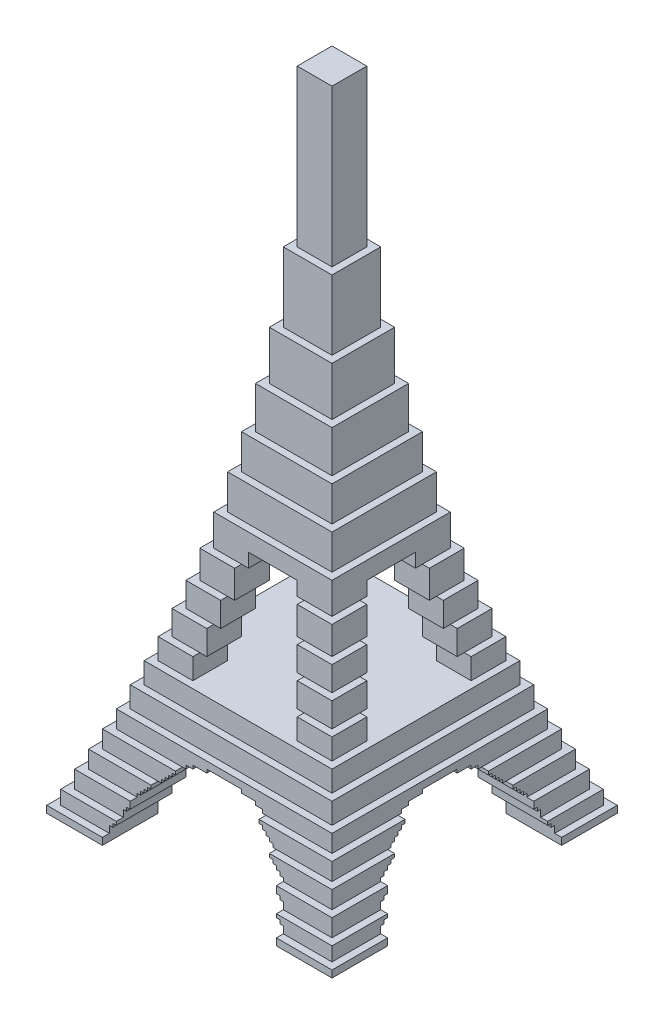
from build123d import *

# Parameters (mm, degrees)
SKIZZE4_W                            = 41
SKIZZE4_H                            = 108
AUFSATZ_LINEAR_AUSTRAGEN2_DEPTH      = 20.5
AUFSATZ_LINEAR_AUSTRAGEN2_DEPTH_BACK = 20.5
SCHNITT_LINEAR_AUSTRAGEN1_DEPTH      = 21.5
SCHNITT_LINEAR_AUSTRAGEN2_DEPTH      = 21.5
SCHNITT_LINEAR_AUSTRAGEN5_DEPTH      = 21.5
SPIEGELN1_COPY_1_DEPTH               = 21.5
SPIEGELN1_COPY_2_DEPTH               = 21.5
SPIEGELN1_COPY_3_DEPTH               = 21.5


with BuildPart() as part:
    # Skizze4 → Aufsatz-Linear austragen2 (new body, two sides)
    with BuildSketch(Plane.XY) as aufsatz_linear_austragen2_sk:
        with Locations((0, 54)):
            Rectangle(SKIZZE4_W, SKIZZE4_H)
    extrude(amount=AUFSATZ_LINEAR_AUSTRAGEN2_DEPTH)
    extrude(aufsatz_linear_austragen2_sk.sketch, amount=-AUFSATZ_LINEAR_AUSTRAGEN2_DEPTH_BACK)

    # Skizze2 → Schnitt-Linear austragen1 (cut, symmetric)
    with BuildSketch(Plane.XY):
        Polygon((-12.5, 0), (-12.5, 2), (-12, 2), (-12, 2.5), (-11.5, 2.5), (-11.5, 4), (-11, 4), (-11, 4.5), (-10.5, 4.5), (-10.5, 6), (-10, 6), (-10, 6.5), (-9.5, 6.5), (-9.5, 7), (-9, 7), (-9, 7.5), (-8.5, 7.5), (-8.5, 8), (-8, 8), (-8, 8.5), (-7.5, 8.5), (-7.5, 9), (-7, 9), (-7, 9.5), (-6.5, 9.5), (-6.5, 10), (-6, 10), (-6, 10.5), (-5.5, 10.5), (-5.5, 11), (-4.5, 11), (-4.5, 11.5), (-2.5, 11.5), (-2.5, 12), (0, 12), (0, 0), align=None)
    schnitt_linear_austragen1 = extrude(amount=SCHNITT_LINEAR_AUSTRAGEN1_DEPTH, both=True, mode=Mode.SUBTRACT)

    # Skizze5 → Schnitt-Linear austragen2 (cut, symmetric)
    with BuildSketch(Plane.XY):
        Polygon((-20.5, 0), (-30.5, 0), (-30.5, 118), (0, 118), (0, 93), (-2.5, 93), (-2.5, 70.5), (-3.5, 70.5), (-3.5, 60.5), (-4.5, 60.5), (-4.5, 53.5), (-5.5, 53.5), (-5.5, 47.5), (-6.5, 47.5), (-6.5, 42.5), (-7.5, 42.5), (-7.5, 37.5), (-8.5, 37.5), (-8.5, 33), (-9.5, 33), (-9.5, 29), (-10.5, 29), (-10.5, 25.5), (-11.5, 25.5), (-11.5, 22), (-12.5, 22), (-12.5, 19), (-13.5, 19), (-13.5, 16), (-14.5, 16), (-14.5, 13), (-15.5, 13), (-15.5, 10.5), (-16.5, 10.5), (-16.5, 8), (-17.5, 8), (-17.5, 5.5), (-18.5, 5.5), (-18.5, 3), (-19.5, 3), (-19.5, 1), (-20.5, 1), align=None)
    schnitt_linear_austragen2 = extrude(amount=SCHNITT_LINEAR_AUSTRAGEN2_DEPTH, both=True, mode=Mode.SUBTRACT)

    # Skizze6 → Schnitt-Linear austragen5 (cut, symmetric)
    with BuildSketch(Plane.XY):
        Polygon((0, 19), (-7.5, 19), (-7.5, 22), (-6.5, 22), (-6.5, 25.5), (-5.5, 25.5), (-5.5, 29), (-4.5, 29), (-4.5, 33), (-3.5, 33), (-3.5, 35), (0, 35), align=None)
    schnitt_linear_austragen5 = extrude(amount=SCHNITT_LINEAR_AUSTRAGEN5_DEPTH, both=True, mode=Mode.SUBTRACT)

    # Spiegeln2: Schnitt-Linear austragen1, Schnitt-Linear austragen2, Schnitt-Linear austragen5 across plane
    add(schnitt_linear_austragen1.mirror(Plane(origin=(0, 0, 0), x_dir=(0, 0, 1), z_dir=(1, 0, 0))), mode=Mode.SUBTRACT)
    add(schnitt_linear_austragen2.mirror(Plane(origin=(0, 0, 0), x_dir=(0, 0, 1), z_dir=(1, 0, 0))), mode=Mode.SUBTRACT)
    add(schnitt_linear_austragen5.mirror(Plane(origin=(0, 0, 0), x_dir=(0, 0, 1), z_dir=(1, 0, 0))), mode=Mode.SUBTRACT)

    # Spiegeln1: Schnitt-Linear austragen5, Schnitt-Linear austragen1, Schnitt-Linear austragen2 across plane
    add(schnitt_linear_austragen5.mirror(Plane(origin=(0, 0, 0), x_dir=(-0.707106781, 0, 0.707106781), z_dir=(0.707106781, 0, 0.707106781))), mode=Mode.SUBTRACT)
    add(schnitt_linear_austragen1.mirror(Plane(origin=(0, 0, 0), x_dir=(-0.707106781, 0, 0.707106781), z_dir=(0.707106781, 0, 0.707106781))), mode=Mode.SUBTRACT)
    add(schnitt_linear_austragen2.mirror(Plane(origin=(0, 0, 0), x_dir=(-0.707106781, 0, 0.707106781), z_dir=(0.707106781, 0, 0.707106781))), mode=Mode.SUBTRACT)

    # Spiegeln1 copy 1 sketch → Spiegeln1 copy 1 (cut, symmetric)
    with BuildSketch(Plane.ZY):
        Polygon((-12.5, 0), (-12.5, 2), (-12, 2), (-12, 2.5), (-11.5, 2.5), (-11.5, 4), (-11, 4), (-11, 4.5), (-10.5, 4.5), (-10.5, 6), (-10, 6), (-10, 6.5), (-9.5, 6.5), (-9.5, 7), (-9, 7), (-9, 7.5), (-8.5, 7.5), (-8.5, 8), (-8, 8), (-8, 8.5), (-7.5, 8.5), (-7.5, 9), (-7, 9), (-7, 9.5), (-6.5, 9.5), (-6.5, 10), (-6, 10), (-6, 10.5), (-5.5, 10.5), (-5.5, 11), (-4.5, 11), (-4.5, 11.5), (-2.5, 11.5), (-2.5, 12), (0, 12), (0, 0), align=None)
    extrude(amount=SPIEGELN1_COPY_1_DEPTH, both=True, mode=Mode.SUBTRACT)

    # Spiegeln1 copy 2 sketch → Spiegeln1 copy 2 (cut, symmetric)
    with BuildSketch(Plane.ZY):
        Polygon((-20.5, 0), (-30.5, 0), (-30.5, 118), (0, 118), (0, 93), (-2.5, 93), (-2.5, 70.5), (-3.5, 70.5), (-3.5, 60.5), (-4.5, 60.5), (-4.5, 53.5), (-5.5, 53.5), (-5.5, 47.5), (-6.5, 47.5), (-6.5, 42.5), (-7.5, 42.5), (-7.5, 37.5), (-8.5, 37.5), (-8.5, 33), (-9.5, 33), (-9.5, 29), (-10.5, 29), (-10.5, 25.5), (-11.5, 25.5), (-11.5, 22), (-12.5, 22), (-12.5, 19), (-13.5, 19), (-13.5, 16), (-14.5, 16), (-14.5, 13), (-15.5, 13), (-15.5, 10.5), (-16.5, 10.5), (-16.5, 8), (-17.5, 8), (-17.5, 5.5), (-18.5, 5.5), (-18.5, 3), (-19.5, 3), (-19.5, 1), (-20.5, 1), align=None)
    extrude(amount=SPIEGELN1_COPY_2_DEPTH, both=True, mode=Mode.SUBTRACT)

    # Spiegeln1 copy 3 sketch → Spiegeln1 copy 3 (cut, symmetric)
    with BuildSketch(Plane.ZY):
        Polygon((0, 19), (-7.5, 19), (-7.5, 22), (-6.5, 22), (-6.5, 25.5), (-5.5, 25.5), (-5.5, 29), (-4.5, 29), (-4.5, 33), (-3.5, 33), (-3.5, 35), (0, 35), align=None)
    extrude(amount=SPIEGELN1_COPY_3_DEPTH, both=True, mode=Mode.SUBTRACT)


solid = part.part
